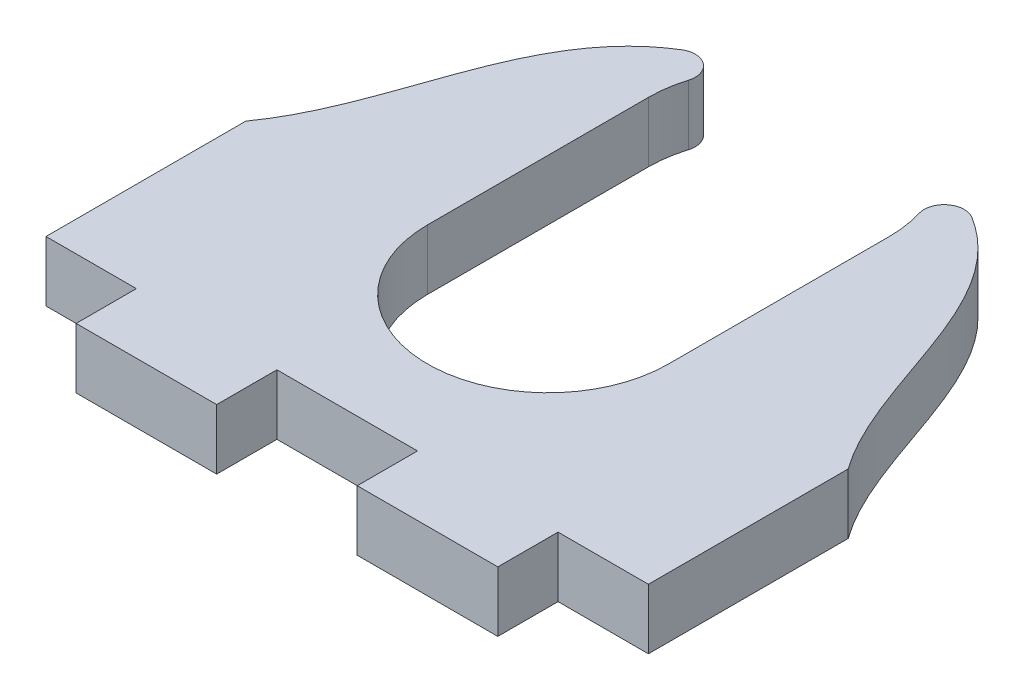
from build123d import *

# Parameters (mm, degrees)
SKETCH1_W           = 30
SKETCH1_H           = 25
SKETCH1_W_2         = 7
SKETCH1_H_2         = 3
BOSS_EXTRUDE1_DEPTH = 3
CUT_EXTRUDE1_DEPTH  = 4
FILLET1_R           = 1


with BuildPart() as part:
    # Sketch1 → Boss-Extrude1 (new body)
    with BuildSketch(Plane(origin=(0, 0, 0), x_dir=(1, 0, 0), z_dir=(0, 1, 0))):
        Rectangle(SKETCH1_W, SKETCH1_H)
        with Locations((-7, -14)):
            Rectangle(SKETCH1_W_2, SKETCH1_H_2)
        with Locations((7, -14)):
            Rectangle(SKETCH1_W_2, SKETCH1_H_2)
    extrude(amount=BOSS_EXTRUDE1_DEPTH)

    # Sketch2 → Cut-Extrude1 (cut, through all)
    with BuildSketch(Plane(origin=(0, 3, 0), x_dir=(1, 0, 0), z_dir=(0, 1, 0))):
        with BuildLine():
            Line((-4.472135955, 12.5), (-15, 12.5))
            Line((-15, 12.5), (-15, -2.54996447))
            add(Edge.make_bspline(
                [(-15, -2.54996447), (-11.338987125, 2.558357454), (-12.102816027, 10.660548238), (-4.472135955, 12.5)],
                knots=[0, 0, 0, 0, 1, 1, 1, 1], degree=3))
        make_face()
        with BuildLine():
            Line((6, 8.5), (6, -2.5))
            ThreePointArc((6, -2.5), (0, -8.5), (-6, -2.5))
            Line((-6, -2.5), (-6, 8.5))
            ThreePointArc((-6, 8.5), (0, 14.5), (6, 8.5))
        make_face()
        with BuildLine():
            Line((15, 12.5), (15, -2.54996447))
            add(Edge.make_bspline(
                [(15, -2.54996447), (11.338987125, 2.558357454), (12.102816027, 10.660548238), (4.472135955, 12.5)],
                knots=[0, 0, 0, 0, 1, 1, 1, 1], degree=3))
            Line((4.472135955, 12.5), (15, 12.5))
        make_face()
    extrude(amount=-CUT_EXTRUDE1_DEPTH, mode=Mode.SUBTRACT)

    # Fillet1
    fillet1_edges = [part.edges().sort_by_distance(p)[0] for p in [
        (-4.472135955, 1.5, -12.5),
        (4.472135955, 1.5, -12.5),
    ]]
    fillet(fillet1_edges, radius=FILLET1_R)


solid = part.part
